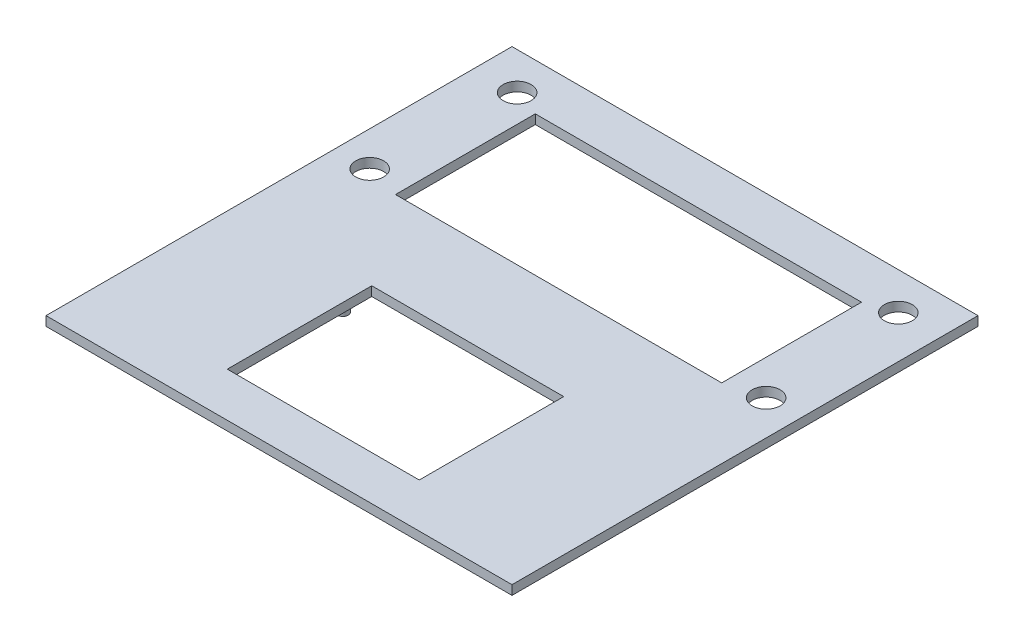
from build123d import *

# Parameters (mm, degrees)
SKETCH1_W           = 63.5
SKETCH1_H           = 63.5
BOSS_EXTRUDE1_DEPTH = 1.27
SKETCH2_R           = 1.905
CUT_EXTRUDE1_DEPTH  = 1.27
SKETCH3_W           = 44.45
SKETCH3_H           = 19.05
CUT_EXTRUDE2_DEPTH  = 1.27
SKETCH4_R           = 0.73025
BOSS_EXTRUDE2_DEPTH = 3.81
CUT_EXTRUDE3_REACH  = 5.81
SKETCH5_W           = 26.162
SKETCH5_H           = 19.685


with BuildPart() as part:
    # Sketch1 → Boss-Extrude1 (new body)
    with BuildSketch(Plane(origin=(0, 0, 0), x_dir=(1, 0, 0), z_dir=(0, 1, 0))):
        Rectangle(SKETCH1_W, SKETCH1_H)
    extrude(amount=BOSS_EXTRUDE1_DEPTH)

    # Sketch2 → Cut-Extrude1 (cut)
    with BuildSketch(Plane(origin=(0, 1.27, 0), x_dir=(1, 0, 0), z_dir=(0, 1, 0))):
        with Locations((27.0129, 7.62)):
            Circle(SKETCH2_R)
        with Locations((25.9715, 26.67)):
            Circle(SKETCH2_R)
        with Locations((-27.0129, 7.62)):
            Circle(SKETCH2_R)
        with Locations((-25.9715, 26.67)):
            Circle(SKETCH2_R)
    extrude(amount=-CUT_EXTRUDE1_DEPTH, mode=Mode.SUBTRACT)

    # Sketch3 → Cut-Extrude2 (cut)
    with BuildSketch(Plane(origin=(0, 1.27, 0), x_dir=(1, 0, 0), z_dir=(0, 1, 0))):
        with Locations((0, 15.875)):
            Rectangle(SKETCH3_W, SKETCH3_H)
    extrude(amount=-CUT_EXTRUDE2_DEPTH, mode=Mode.SUBTRACT)

    # Sketch4 → Boss-Extrude2 (add)
    with BuildSketch(Plane(origin=(0, 1.27, 0), x_dir=(1, 0, 0), z_dir=(0, 1, 0))):
        with Locations((-15.748, -7.3025)):
            Circle(SKETCH4_R)
        with Locations((15.748, -19.3167)):
            Circle(SKETCH4_R)
    extrude(amount=-BOSS_EXTRUDE2_DEPTH)

    # Sketch5 → Cut-Extrude3 (cut, up to next)
    with BuildSketch(Plane(origin=(0, 1.27, 0), x_dir=(1, 0, 0), z_dir=(0, 1, 0)), mode=Mode.PRIVATE) as cut_extrude3_sk1:
        with Locations((0, -15.875)):
            Rectangle(SKETCH5_W, SKETCH5_H)
    cut_extrude3_tool1 = extrude(cut_extrude3_sk1.sketch, amount=-CUT_EXTRUDE3_REACH, mode=Mode.PRIVATE) & part.part
    add(cut_extrude3_tool1.solids().sort_by_distance((0, 1.27, 15.875))[0], mode=Mode.SUBTRACT)


solid = part.part
